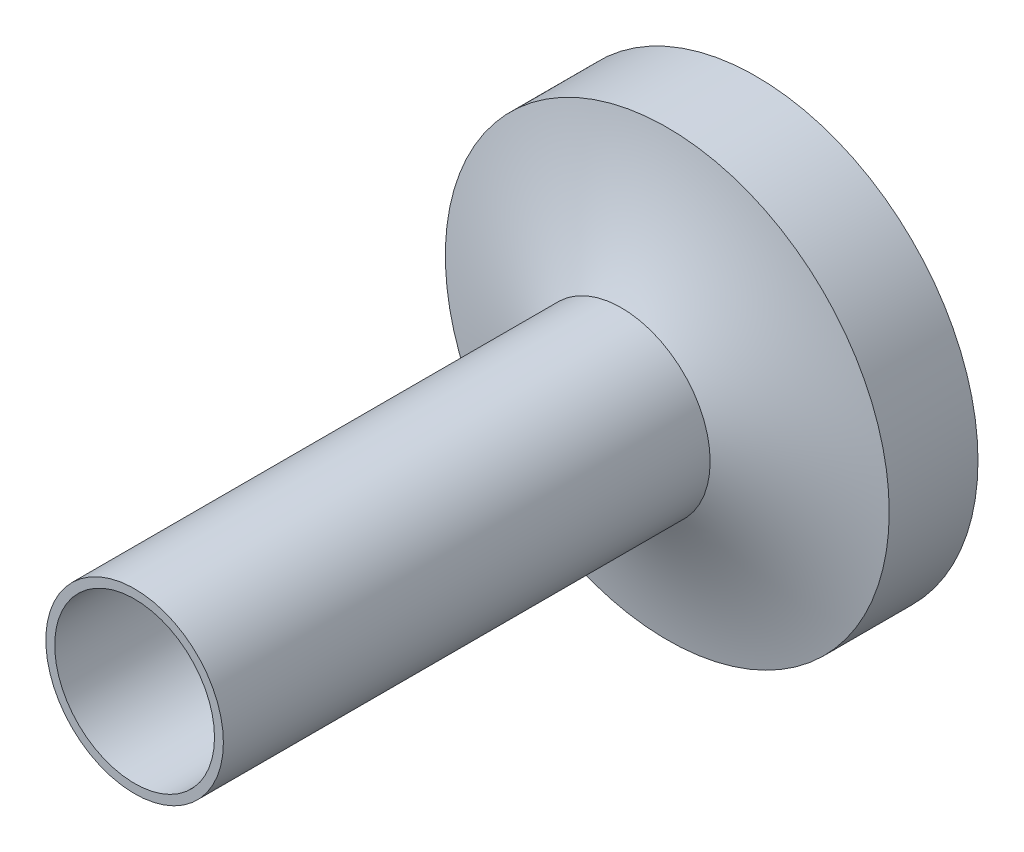
from build123d import *

# Parameters (mm, degrees)
CROQUIS1_R              = 2.5
CROQUIS1_R_2            = 1
SALIENTE_EXTRUIR1_DEPTH = 1
CROQUIS2_R              = 1
SALIENTE_EXTRUIR2_DEPTH = 6
VACIADO2_T              = -0.1


with BuildPart() as part:
    # Croquis1 → Saliente-Extruir1 (new body)
    with BuildSketch(Plane.XY):
        Circle(CROQUIS1_R)
        Circle(CROQUIS1_R_2, mode=Mode.SUBTRACT)
    extrude(amount=SALIENTE_EXTRUIR1_DEPTH)



with BuildPart() as body_2:
    # Croquis2 → Saliente-Extruir2 (new body)
    with BuildSketch(Plane.XY.offset(1)):
        Circle(CROQUIS2_R)
    extrude(amount=SALIENTE_EXTRUIR2_DEPTH)

    # Vaciado2
    vaciado2_openings = [body_2.faces().sort_by_distance(p)[0] for p in [
        (0, 0, 7),
        (0, 0, 1),
    ]]
    offset(amount=VACIADO2_T, openings=vaciado2_openings, kind=Kind.INTERSECTION)


with BuildPart() as part_1:
    add(part.part)

    add(body_2.part)  # Revolución2 merges body 2
    # Croquis3 → Revolución2 (revolve)
    with BuildSketch(Plane(origin=(0, 0, 0), x_dir=(0, 0, -1), z_dir=(1, 0, 0)), mode=Mode.PRIVATE) as revoluci_n2_sk:
        with BuildLine():
            Line((-1, 2.5), (-1, 1))
            Line((-1, 1), (-1.517000999, 1))
            add(Edge.make_bspline(
                [(-1.517000999, 1), (-1.132819845, 1.729659773), (-1, 2.5)],
                knots=[0, 0, 0, 1, 1, 1], degree=2))
        make_face()
    revolve(revoluci_n2_sk.sketch.rotate(Axis((0, 0, 7.040846827), (0, 0, -1)), 90), axis=Axis((0, 0, 7.040846827), (0, 0, -1)))


solid = part_1.part
